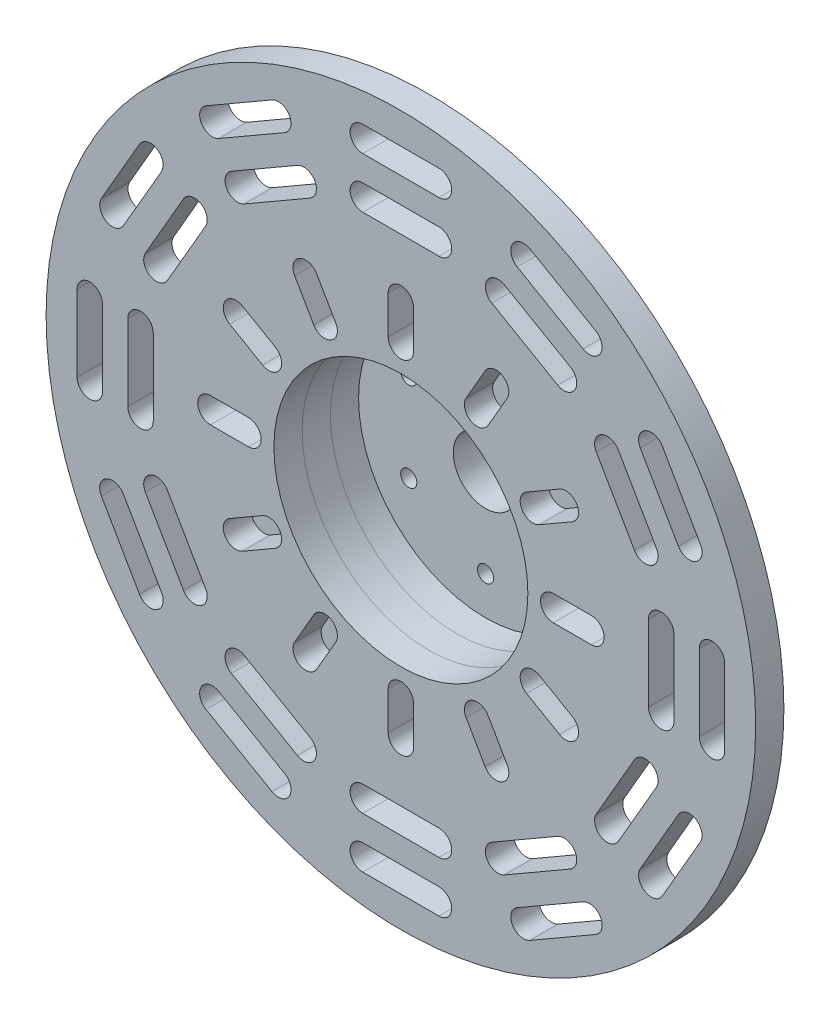
from build123d import *

# Parameters (mm, degrees)
SKETCH4_R           = 75
SKETCH4_R_2         = 12.7
SKETCH4_R_3         = 3.175
BOSS_EXTRUDE1_DEPTH = 11.1125
SKETCH5_R           = 75
SKETCH5_R_2         = 50
BOSS_EXTRUDE2_DEPTH = 11.1125
SKETCH6_R           = 90
SKETCH6_R_2         = 50
BOSS_EXTRUDE3_DEPTH = 11.1125
SKETCH7_R           = 139.7
SKETCH7_R_2         = 50
BOSS_EXTRUDE4_DEPTH = 11.1125


with BuildPart() as part:
    # Sketch4 → Boss-Extrude1 (new body)
    with BuildSketch(Plane.XY):
        Circle(SKETCH4_R)
        Circle(SKETCH4_R_2, mode=Mode.SUBTRACT)
        with Locations((30.245937227, 17.4625)):
            Circle(SKETCH4_R_3, mode=Mode.SUBTRACT)
        with Locations((-30.245937227, 17.4625)):
            Circle(SKETCH4_R_3, mode=Mode.SUBTRACT)
        with Locations((0, -34.925)):
            Circle(SKETCH4_R_3, mode=Mode.SUBTRACT)
        with BuildLine():
            ThreePointArc((-2.24506403, 37.17006403), (1.029072671, 31.921396425), (0.396601421, 38.07513211))
            ThreePointArc((0.396601421, 38.07513211), (-1.029072671, 37.928603575), (-2.24506403, 37.17006403))
        make_face(mode=Mode.SUBTRACT)
        with BuildLine():
            ThreePointArc((-31.067687695, -20.529314498), (-28.159276563, -15.069495137), (-33.17233237, -18.69409915))
            ThreePointArc((-33.17233237, -18.69409915), (-32.332597891, -19.855504863), (-31.067687695, -20.529314498))
        make_face(mode=Mode.SUBTRACT)
        with BuildLine():
            ThreePointArc((33.312751726, -16.640749532), (27.130203893, -16.851901288), (32.77573095, -19.381032961))
            ThreePointArc((32.77573095, -19.381032961), (33.361670562, -18.073098712), (33.312751726, -16.640749532))
        make_face(mode=Mode.SUBTRACT)
    extrude(amount=BOSS_EXTRUDE1_DEPTH)


with BuildPart() as body_2:
    # Sketch5 → Boss-Extrude2 (new body)
    with BuildSketch(Plane.XY.offset(11.1125)):
        Circle(SKETCH5_R)
        Circle(SKETCH5_R_2, mode=Mode.SUBTRACT)
    extrude(amount=BOSS_EXTRUDE2_DEPTH)


with BuildPart() as body_3:
    # Sketch6 → Boss-Extrude3 (new body)
    with BuildSketch(Plane.XY.offset(22.225)):
        Circle(SKETCH6_R)
        Circle(SKETCH6_R_2, mode=Mode.SUBTRACT)
    extrude(amount=BOSS_EXTRUDE3_DEPTH)


with BuildPart() as body_4:
    # Sketch7 → Boss-Extrude4 (new body)
    with BuildSketch(Plane.XY.offset(33.3375)):
        Circle(SKETCH7_R)
        Circle(SKETCH7_R_2, mode=Mode.SUBTRACT)
        with BuildLine():
            Line((-5, -60), (-5, -75))
            ThreePointArc((-5, -75), (0, -80), (5, -75))
            Line((5, -75), (5, -60))
            ThreePointArc((5, -60), (0, -55), (-5, -60))
        make_face(mode=Mode.SUBTRACT)
        with BuildLine():
            Line((15, -117.5), (-15, -117.5))
            ThreePointArc((-15, -117.5), (-20, -122.5), (-15, -127.5))
            Line((-15, -127.5), (15, -127.5))
            ThreePointArc((15, -127.5), (20, -122.5), (15, -117.5))
        make_face(mode=Mode.SUBTRACT)
        with BuildLine():
            Line((-45.759618943, -109.257984945), (-71.740381057, -94.257984945))
            ThreePointArc((-71.740381057, -94.257984945), (-78.570508076, -96.088111964), (-76.740381057, -102.918238983))
            Line((-76.740381057, -102.918238983), (-50.759618943, -117.918238983))
            ThreePointArc((-50.759618943, -117.918238983), (-43.929491924, -116.088111964), (-45.759618943, -109.257984945))
        make_face(mode=Mode.SUBTRACT)
        with BuildLine():
            Line((-33.169872981, -67.451905284), (-25.669872981, -54.461524227))
            ThreePointArc((-25.669872981, -54.461524227), (-27.5, -47.631397208), (-34.330127019, -49.461524227))
            Line((-34.330127019, -49.461524227), (-41.830127019, -62.451905284))
            ThreePointArc((-41.830127019, -62.451905284), (-40, -69.282032303), (-33.169872981, -67.451905284))
        make_face(mode=Mode.SUBTRACT)
        with BuildLine():
            Line((-54.461524227, -25.669872981), (-67.451905284, -33.169872981))
            ThreePointArc((-67.451905284, -33.169872981), (-69.282032303, -40), (-62.451905284, -41.830127019))
            Line((-62.451905284, -41.830127019), (-49.461524227, -34.330127019))
            ThreePointArc((-49.461524227, -34.330127019), (-47.631397208, -27.5), (-54.461524227, -25.669872981))
        make_face(mode=Mode.SUBTRACT)
        with BuildLine():
            Line((-35.759618943, -91.937476869), (-61.740381057, -76.937476869))
            ThreePointArc((-61.740381057, -76.937476869), (-68.570508076, -78.767603888), (-66.740381057, -85.597730907))
            Line((-66.740381057, -85.597730907), (-40.759618943, -100.597730907))
            ThreePointArc((-40.759618943, -100.597730907), (-33.929491924, -98.767603888), (-35.759618943, -91.937476869))
        make_face(mode=Mode.SUBTRACT)
        with BuildLine():
            Line((-94.257984945, -71.740381057), (-109.257984945, -45.759618943))
            ThreePointArc((-109.257984945, -45.759618943), (-116.088111964, -43.929491924), (-117.918238983, -50.759618943))
            Line((-117.918238983, -50.759618943), (-102.918238983, -76.740381057))
            ThreePointArc((-102.918238983, -76.740381057), (-96.088111964, -78.570508076), (-94.257984945, -71.740381057))
        make_face(mode=Mode.SUBTRACT)
        with BuildLine():
            Line((-76.937476869, -61.740381057), (-91.937476869, -35.759618943))
            ThreePointArc((-91.937476869, -35.759618943), (-98.767603888, -33.929491924), (-100.597730907, -40.759618943))
            Line((-100.597730907, -40.759618943), (-85.597730907, -66.740381057))
            ThreePointArc((-85.597730907, -66.740381057), (-78.767603888, -68.570508076), (-76.937476869, -61.740381057))
        make_face(mode=Mode.SUBTRACT)
        with BuildLine():
            Line((-75, -5), (-60, -5))
            ThreePointArc((-60, -5), (-55, 0), (-60, 5))
            Line((-60, 5), (-75, 5))
            ThreePointArc((-75, 5), (-80, 0), (-75, -5))
        make_face(mode=Mode.SUBTRACT)
        with BuildLine():
            Line((-15, -107.5), (15, -107.5))
            ThreePointArc((15, -107.5), (20, -102.5), (15, -97.5))
            Line((15, -97.5), (-15, -97.5))
            ThreePointArc((-15, -97.5), (-20, -102.5), (-15, -107.5))
        make_face(mode=Mode.SUBTRACT)
        with BuildLine():
            Line((-49.461524227, 34.330127019), (-62.451905284, 41.830127019))
            ThreePointArc((-62.451905284, 41.830127019), (-69.282032303, 40), (-67.451905284, 33.169872981))
            Line((-67.451905284, 33.169872981), (-54.461524227, 25.669872981))
            ThreePointArc((-54.461524227, 25.669872981), (-47.631397208, 27.5), (-49.461524227, 34.330127019))
        make_face(mode=Mode.SUBTRACT)
        with BuildLine():
            Line((-127.5, 15), (-127.5, -15))
            ThreePointArc((-127.5, -15), (-122.5, -20), (-117.5, -15))
            Line((-117.5, -15), (-117.5, 15))
            ThreePointArc((-117.5, 15), (-122.5, 20), (-127.5, 15))
        make_face(mode=Mode.SUBTRACT)
        with BuildLine():
            Line((-97.5, -15), (-97.5, 15))
            ThreePointArc((-97.5, 15), (-102.5, 20), (-107.5, 15))
            Line((-107.5, 15), (-107.5, -15))
            ThreePointArc((-107.5, -15), (-102.5, -20), (-97.5, -15))
        make_face(mode=Mode.SUBTRACT)
        with BuildLine():
            Line((-109.257984945, 45.759618943), (-94.257984945, 71.740381057))
            ThreePointArc((-94.257984945, 71.740381057), (-96.088111964, 78.570508076), (-102.918238983, 76.740381057))
            Line((-102.918238983, 76.740381057), (-117.918238983, 50.759618943))
            ThreePointArc((-117.918238983, 50.759618943), (-116.088111964, 43.929491924), (-109.257984945, 45.759618943))
        make_face(mode=Mode.SUBTRACT)
        with BuildLine():
            Line((-91.937476869, 35.759618943), (-76.937476869, 61.740381057))
            ThreePointArc((-76.937476869, 61.740381057), (-78.767603888, 68.570508076), (-85.597730907, 66.740381057))
            Line((-85.597730907, 66.740381057), (-100.597730907, 40.759618943))
            ThreePointArc((-100.597730907, 40.759618943), (-98.767603888, 33.929491924), (-91.937476869, 35.759618943))
        make_face(mode=Mode.SUBTRACT)
        with BuildLine():
            Line((-71.740381057, 94.257984945), (-45.759618943, 109.257984945))
            ThreePointArc((-45.759618943, 109.257984945), (-43.929491924, 116.088111964), (-50.759618943, 117.918238983))
            Line((-50.759618943, 117.918238983), (-76.740381057, 102.918238983))
            ThreePointArc((-76.740381057, 102.918238983), (-78.570508076, 96.088111964), (-71.740381057, 94.257984945))
        make_face(mode=Mode.SUBTRACT)
        with BuildLine():
            Line((-25.669872981, 54.461524227), (-33.169872981, 67.451905284))
            ThreePointArc((-33.169872981, 67.451905284), (-40, 69.282032303), (-41.830127019, 62.451905284))
            Line((-41.830127019, 62.451905284), (-34.330127019, 49.461524227))
            ThreePointArc((-34.330127019, 49.461524227), (-27.5, 47.631397208), (-25.669872981, 54.461524227))
        make_face(mode=Mode.SUBTRACT)
        with BuildLine():
            Line((5, 60), (5, 75))
            ThreePointArc((5, 75), (0, 80), (-5, 75))
            Line((-5, 75), (-5, 60))
            ThreePointArc((-5, 60), (0, 55), (5, 60))
        make_face(mode=Mode.SUBTRACT)
        with BuildLine():
            Line((-61.740381057, 76.937476869), (-35.759618943, 91.937476869))
            ThreePointArc((-35.759618943, 91.937476869), (-33.929491924, 98.767603888), (-40.759618943, 100.597730907))
            Line((-40.759618943, 100.597730907), (-66.740381057, 85.597730907))
            ThreePointArc((-66.740381057, 85.597730907), (-68.570508076, 78.767603888), (-61.740381057, 76.937476869))
        make_face(mode=Mode.SUBTRACT)
        with BuildLine():
            Line((-15, 117.5), (15, 117.5))
            ThreePointArc((15, 117.5), (20, 122.5), (15, 127.5))
            Line((15, 127.5), (-15, 127.5))
            ThreePointArc((-15, 127.5), (-20, 122.5), (-15, 117.5))
        make_face(mode=Mode.SUBTRACT)
        with BuildLine():
            Line((-15, 97.5), (15, 97.5))
            ThreePointArc((15, 97.5), (20, 102.5), (15, 107.5))
            Line((15, 107.5), (-15, 107.5))
            ThreePointArc((-15, 107.5), (-20, 102.5), (-15, 97.5))
        make_face(mode=Mode.SUBTRACT)
        with BuildLine():
            Line((45.759618943, 109.257984945), (71.740381057, 94.257984945))
            ThreePointArc((71.740381057, 94.257984945), (78.570508076, 96.088111964), (76.740381057, 102.918238983))
            Line((76.740381057, 102.918238983), (50.759618943, 117.918238983))
            ThreePointArc((50.759618943, 117.918238983), (43.929491924, 116.088111964), (45.759618943, 109.257984945))
        make_face(mode=Mode.SUBTRACT)
        with BuildLine():
            Line((35.759618943, 91.937476869), (61.740381057, 76.937476869))
            ThreePointArc((61.740381057, 76.937476869), (68.570508076, 78.767603888), (66.740381057, 85.597730907))
            Line((66.740381057, 85.597730907), (40.759618943, 100.597730907))
            ThreePointArc((40.759618943, 100.597730907), (33.929491924, 98.767603888), (35.759618943, 91.937476869))
        make_face(mode=Mode.SUBTRACT)
        with BuildLine():
            Line((34.330127019, 49.461524227), (41.830127019, 62.451905284))
            ThreePointArc((41.830127019, 62.451905284), (40, 69.282032303), (33.169872981, 67.451905284))
            Line((33.169872981, 67.451905284), (25.669872981, 54.461524227))
            ThreePointArc((25.669872981, 54.461524227), (27.5, 47.631397208), (34.330127019, 49.461524227))
        make_face(mode=Mode.SUBTRACT)
        with BuildLine():
            Line((94.257984945, 71.740381057), (109.257984945, 45.759618943))
            ThreePointArc((109.257984945, 45.759618943), (116.088111964, 43.929491924), (117.918238983, 50.759618943))
            Line((117.918238983, 50.759618943), (102.918238983, 76.740381057))
            ThreePointArc((102.918238983, 76.740381057), (96.088111964, 78.570508076), (94.257984945, 71.740381057))
        make_face(mode=Mode.SUBTRACT)
        with BuildLine():
            Line((54.461524227, 25.669872981), (67.451905284, 33.169872981))
            ThreePointArc((67.451905284, 33.169872981), (69.282032303, 40), (62.451905284, 41.830127019))
            Line((62.451905284, 41.830127019), (49.461524227, 34.330127019))
            ThreePointArc((49.461524227, 34.330127019), (47.631397208, 27.5), (54.461524227, 25.669872981))
        make_face(mode=Mode.SUBTRACT)
        with BuildLine():
            Line((60, -5), (75, -5))
            ThreePointArc((75, -5), (80, 0), (75, 5))
            Line((75, 5), (60, 5))
            ThreePointArc((60, 5), (55, 0), (60, -5))
        make_face(mode=Mode.SUBTRACT)
        with BuildLine():
            Line((76.937476869, 61.740381057), (91.937476869, 35.759618943))
            ThreePointArc((91.937476869, 35.759618943), (98.767603888, 33.929491924), (100.597730907, 40.759618943))
            Line((100.597730907, 40.759618943), (85.597730907, 66.740381057))
            ThreePointArc((85.597730907, 66.740381057), (78.767603888, 68.570508076), (76.937476869, 61.740381057))
        make_face(mode=Mode.SUBTRACT)
        with BuildLine():
            Line((49.461524227, -34.330127019), (62.451905284, -41.830127019))
            ThreePointArc((62.451905284, -41.830127019), (69.282032303, -40), (67.451905284, -33.169872981))
            Line((67.451905284, -33.169872981), (54.461524227, -25.669872981))
            ThreePointArc((54.461524227, -25.669872981), (47.631397208, -27.5), (49.461524227, -34.330127019))
        make_face(mode=Mode.SUBTRACT)
        with BuildLine():
            Line((117.5, 15), (117.5, -15))
            ThreePointArc((117.5, -15), (122.5, -20), (127.5, -15))
            Line((127.5, -15), (127.5, 15))
            ThreePointArc((127.5, 15), (122.5, 20), (117.5, 15))
        make_face(mode=Mode.SUBTRACT)
        with BuildLine():
            Line((97.5, 15), (97.5, -15))
            ThreePointArc((97.5, -15), (102.5, -20), (107.5, -15))
            Line((107.5, -15), (107.5, 15))
            ThreePointArc((107.5, 15), (102.5, 20), (97.5, 15))
        make_face(mode=Mode.SUBTRACT)
        with BuildLine():
            Line((109.257984945, -45.759618943), (94.257984945, -71.740381057))
            ThreePointArc((94.257984945, -71.740381057), (96.088111964, -78.570508076), (102.918238983, -76.740381057))
            Line((102.918238983, -76.740381057), (117.918238983, -50.759618943))
            ThreePointArc((117.918238983, -50.759618943), (116.088111964, -43.929491924), (109.257984945, -45.759618943))
        make_face(mode=Mode.SUBTRACT)
        with BuildLine():
            Line((91.937476869, -35.759618943), (76.937476869, -61.740381057))
            ThreePointArc((76.937476869, -61.740381057), (78.767603888, -68.570508076), (85.597730907, -66.740381057))
            Line((85.597730907, -66.740381057), (100.597730907, -40.759618943))
            ThreePointArc((100.597730907, -40.759618943), (98.767603888, -33.929491924), (91.937476869, -35.759618943))
        make_face(mode=Mode.SUBTRACT)
        with BuildLine():
            Line((71.740381057, -94.257984945), (45.759618943, -109.257984945))
            ThreePointArc((45.759618943, -109.257984945), (43.929491924, -116.088111964), (50.759618943, -117.918238983))
            Line((50.759618943, -117.918238983), (76.740381057, -102.918238983))
            ThreePointArc((76.740381057, -102.918238983), (78.570508076, -96.088111964), (71.740381057, -94.257984945))
        make_face(mode=Mode.SUBTRACT)
        with BuildLine():
            Line((61.740381057, -76.937476869), (35.759618943, -91.937476869))
            ThreePointArc((35.759618943, -91.937476869), (33.929491924, -98.767603888), (40.759618943, -100.597730907))
            Line((40.759618943, -100.597730907), (66.740381057, -85.597730907))
            ThreePointArc((66.740381057, -85.597730907), (68.570508076, -78.767603888), (61.740381057, -76.937476869))
        make_face(mode=Mode.SUBTRACT)
        with BuildLine():
            Line((25.669872981, -54.461524227), (33.169872981, -67.451905284))
            ThreePointArc((33.169872981, -67.451905284), (40, -69.282032303), (41.830127019, -62.451905284))
            Line((41.830127019, -62.451905284), (34.330127019, -49.461524227))
            ThreePointArc((34.330127019, -49.461524227), (27.5, -47.631397208), (25.669872981, -54.461524227))
        make_face(mode=Mode.SUBTRACT)
    extrude(amount=BOSS_EXTRUDE4_DEPTH)


solid = Compound([part.part, body_2.part, body_3.part, body_4.part])
